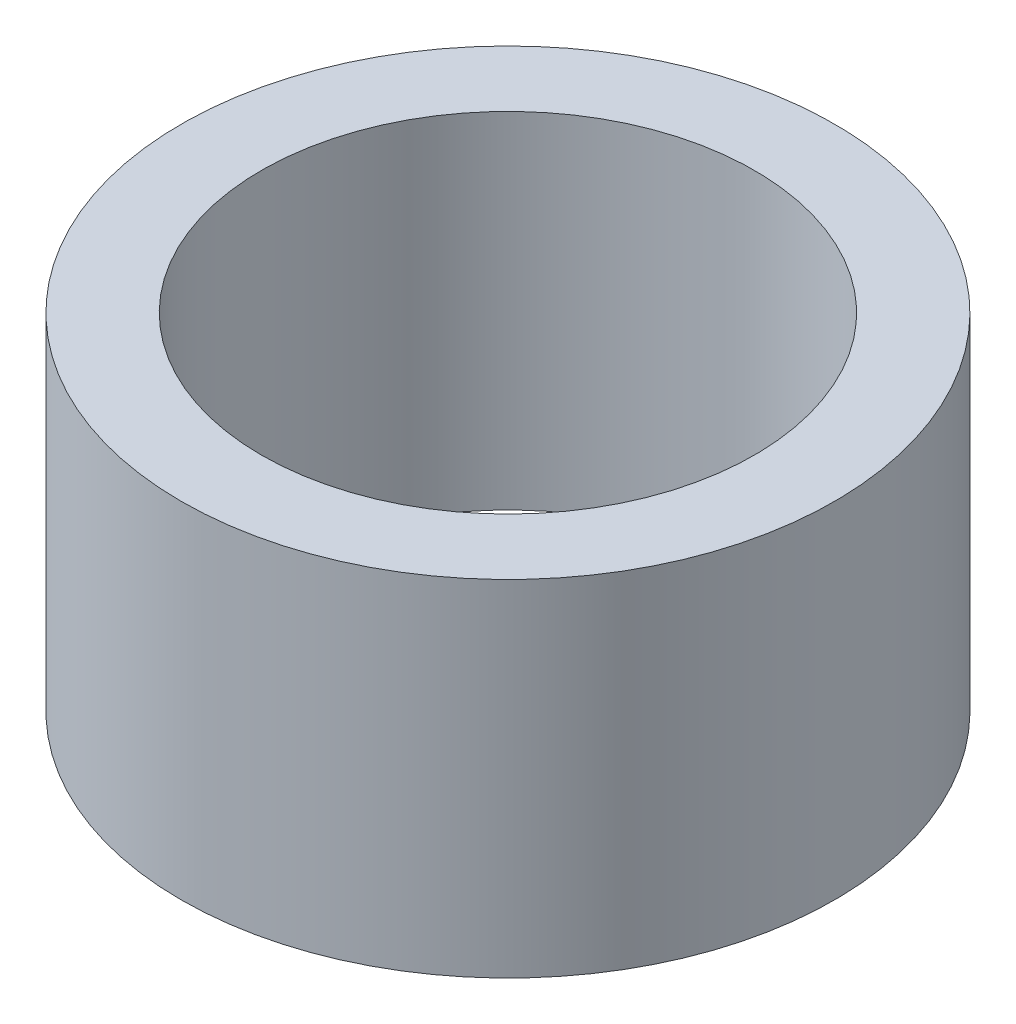
from build123d import *

# Parameters (mm, degrees)
SKETCH1_R           = 13.25
SKETCH1_R_2         = 10
BOSS_EXTRUDE1_DEPTH = 14


with BuildPart() as part:
    # Sketch1 → Boss-Extrude1 (new body)
    with BuildSketch(Plane(origin=(0, 0, 0), x_dir=(1, 0, 0), z_dir=(0, 1, 0))):
        Circle(SKETCH1_R)
        Circle(SKETCH1_R_2, mode=Mode.SUBTRACT)
    extrude(amount=BOSS_EXTRUDE1_DEPTH)


solid = part.part
